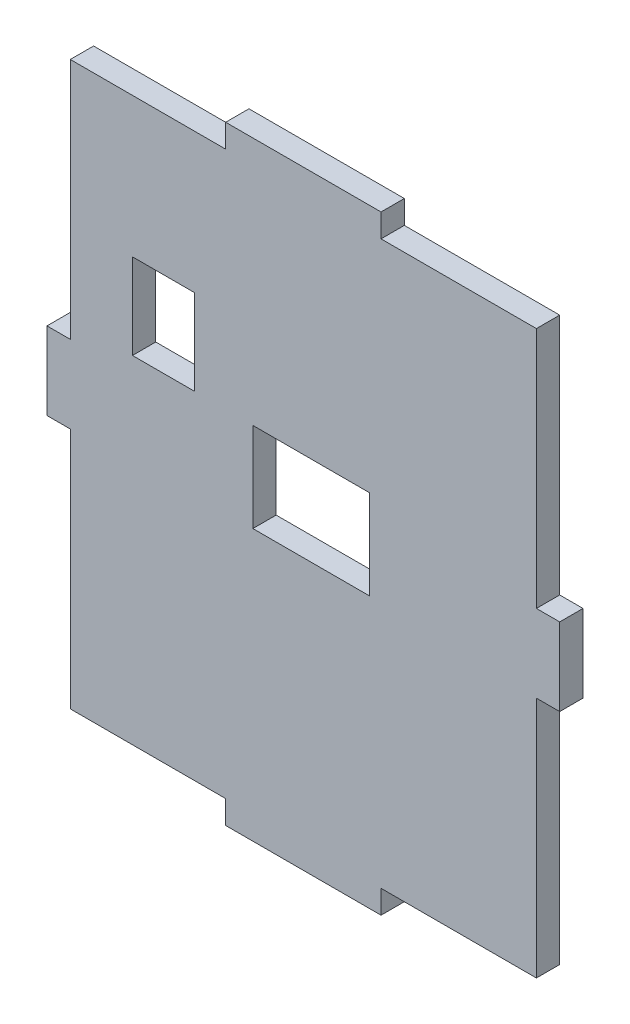
from build123d import *

# Parameters (mm, degrees)
MODEL_W             = 15
MODEL_H             = 11.5
MODEL_W_2           = 8
MODEL_H_2           = 11
BOSS_EXTRUDE1_DEPTH = 3


with BuildPart() as part:
    # Model → Boss-Extrude1 (new body)
    with BuildSketch(Plane.XY):
        Polygon((-66.181799476, -2), (-66.181799476, -5), (-86.181799476, -5), (-86.181799476, -36.2), (-89.181799476, -36.2), (-89.181799476, -46.2), (-86.181799476, -46.2), (-86.181799476, -77.4), (-66.181799476, -77.4), (-66.181799476, -80.4), (-46.181799476, -80.4), (-46.181799476, -77.4), (-26.181799476, -77.4), (-26.181799476, -46.2), (-23.181799476, -46.2), (-23.181799476, -36.2), (-26.181799476, -36.2), (-26.181799476, -5), (-46.181799476, -5), (-46.181799476, -2), align=None)
        with Locations((-55.181799476, -39.795541568)):
            Rectangle(MODEL_W, MODEL_H, mode=Mode.SUBTRACT)
        with Locations((-74.181799476, -28.5)):
            Rectangle(MODEL_W_2, MODEL_H_2, mode=Mode.SUBTRACT)
    extrude(amount=BOSS_EXTRUDE1_DEPTH)


solid = part.part
